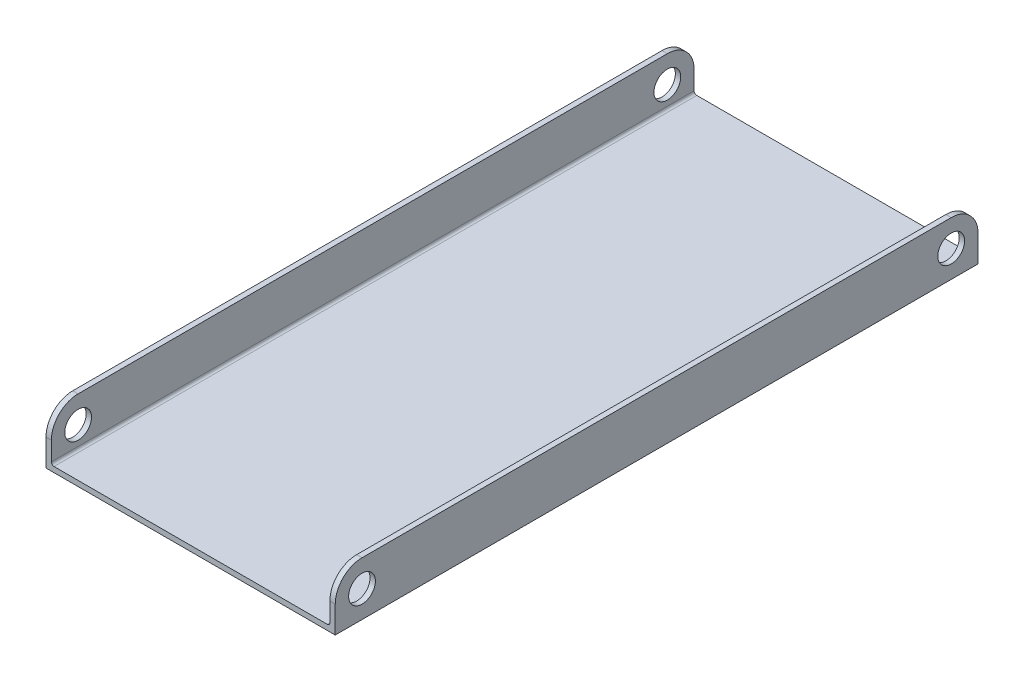
from build123d import *
from OCP.BRepFilletAPI import BRepFilletAPI_MakeFillet

# Parameters (mm, degrees)
BOSS_EXTRUDE1_DEPTH = 152.4
FILLET1_R1          = 6.35
FILLET1_R2          = 0.635
SKETCH3_R           = 3.175
CUT_EXTRUDE1_DEPTH  = 168.601510733


with BuildPart() as part:
    # Sketch2 → Boss-Extrude1 (new body)
    with BuildSketch(Plane.XY):
        Polygon((-34.29, 12.7), (-34.29, 0), (34.29, 0), (34.29, 12.7), (33.02, 12.7), (33.02, 1.27), (-33.02, 1.27), (-33.02, 12.7), align=None)
    extrude(amount=-BOSS_EXTRUDE1_DEPTH)

    # Fillet1: one fillet with a radius per group of edges: ONE call of the kernel's fillet builder (fillet() takes one radius for all edges)
    fillet1_edges_1 = [part.edges().sort_by_distance(p)[0] for p in [
        (33.655, 12.7, 0),
        (-33.655, 12.7, 0),
        (-33.655, 12.7, -152.4),
        (33.655, 12.7, -152.4),
    ]]
    fillet1_edges_2 = [part.edges().sort_by_distance(p)[0] for p in [
        (-33.02, 1.27, -76.2),
        (33.02, 1.27, -76.2),
    ]]
    fillet1 = BRepFilletAPI_MakeFillet(part.part.solid().wrapped)
    for e in fillet1_edges_1:
        fillet1.Add(FILLET1_R1, e.wrapped)
    for e in fillet1_edges_2:
        fillet1.Add(FILLET1_R2, e.wrapped)
    add(Compound.cast(fillet1.Shape()), mode=Mode.REPLACE)

    # Sketch3 → Cut-Extrude1 (cut, through all)
    with BuildSketch(Plane(origin=(34.29, 0, 0), x_dir=(0, 0, -1), z_dir=(1, 0, 0))):
        with Locations((6.35, 6.35)):
            Circle(SKETCH3_R)
        with Locations((146.05, 6.35)):
            Circle(SKETCH3_R)
    extrude(amount=-CUT_EXTRUDE1_DEPTH, mode=Mode.SUBTRACT)


solid = part.part
